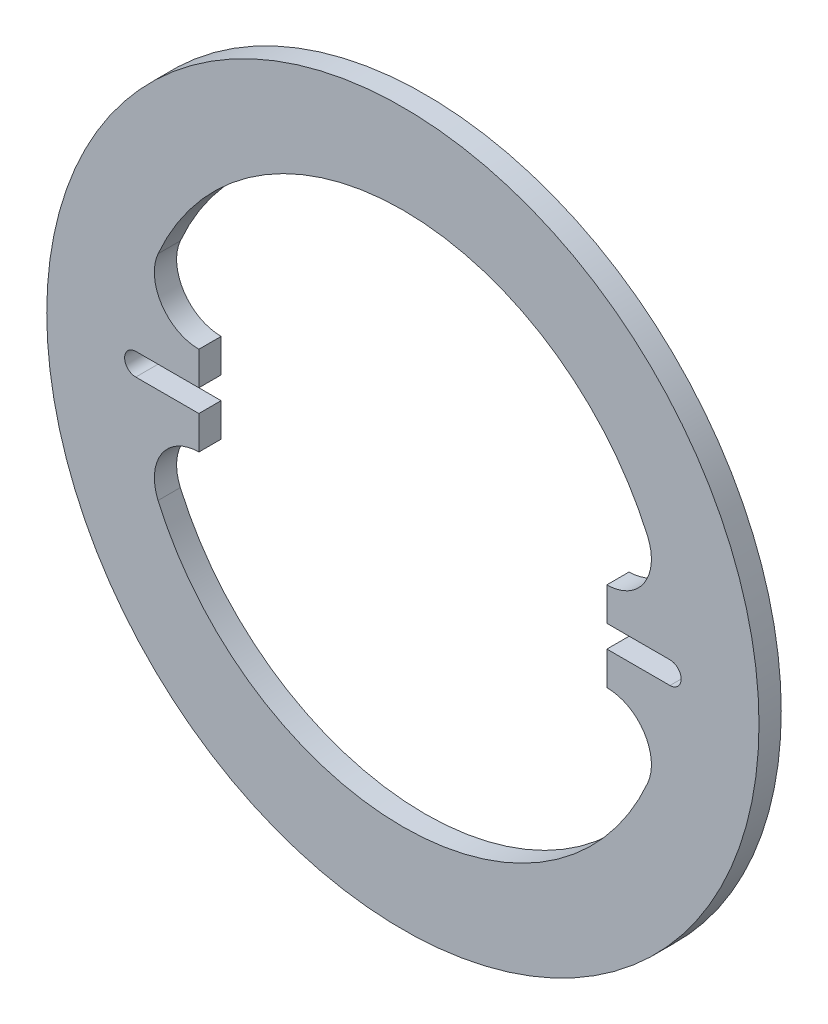
from build123d import *

# Parameters (mm, degrees)
SKETCH1_R           = 101.6
BOSS_EXTRUDE1_DEPTH = 6.35
SKETCH2_R           = 25.4
CUT_EXTRUDE1_DEPTH  = 7.35
CUT_EXTRUDE2_DEPTH  = 7.35
CUT_EXTRUDE3_DEPTH  = 7.35
CUT_EXTRUDE10_DEPTH = 7.35


with BuildPart() as part:
    # Sketch1 → Boss-Extrude1 (new body)
    with BuildSketch(Plane.XY):
        Circle(SKETCH1_R)
    extrude(amount=BOSS_EXTRUDE1_DEPTH)

    # Sketch2 → Cut-Extrude1 (cut, through all)
    with BuildSketch(Plane.XY.offset(6.35)):
        Circle(SKETCH2_R)
    extrude(amount=-CUT_EXTRUDE1_DEPTH, mode=Mode.SUBTRACT)

    # Sketch3 → Cut-Extrude2 (cut, through all)
    with BuildSketch(Plane.XY.offset(6.35)):
        with BuildLine():
            ThreePointArc((69.838453591, 30.48), (0, 76.2), (-69.838453591, 30.48))
            ThreePointArc((-69.838453591, 30.48), (-63.278711326, 13.760257735), (-46.558969061, 20.32))
            ThreePointArc((-46.558969061, 20.32), (0, 50.8), (46.558969061, 20.32))
            ThreePointArc((46.558969061, 20.32), (63.278711326, 13.760257735), (69.838453591, 30.48))
        make_face()
    cut_extrude2 = extrude(amount=-CUT_EXTRUDE2_DEPTH, mode=Mode.SUBTRACT)

    # Mirror1: Cut-Extrude2 across plane
    add(cut_extrude2.mirror(Plane.ZX), mode=Mode.SUBTRACT)

    # Sketch4 → Cut-Extrude3 (cut, through all)
    with BuildSketch(Plane.XY.offset(6.35)):
        with BuildLine():
            Line((76.2, -3.175), (25.4, -3.175))
            ThreePointArc((25.4, -3.175), (22.225, 0), (25.4, 3.175))
            Line((25.4, 3.175), (76.2, 3.175))
            ThreePointArc((76.2, 3.175), (79.375, 0), (76.2, -3.175))
        make_face()
        with BuildLine():
            Line((-76.2, -3.175), (-25.4, -3.175))
            ThreePointArc((-25.4, -3.175), (-22.225, 0), (-25.4, 3.175))
            Line((-25.4, 3.175), (-76.2, 3.175))
            ThreePointArc((-76.2, 3.175), (-79.375, 0), (-76.2, -3.175))
        make_face()
    extrude(amount=-CUT_EXTRUDE3_DEPTH, mode=Mode.SUBTRACT)

    # Sketch14 → Cut-Extrude10 (cut, through all)
    with BuildSketch(Plane.XY.offset(6.35)):
        with BuildLine():
            Line((-58.198711326, -12.7), (-58.198711326, 12.7))
            ThreePointArc((-58.198711326, 12.7), (-51.242634846, 14.774417663), (-46.558969061, 20.32))
            ThreePointArc((-46.558969061, 20.32), (0, 50.8), (46.558969061, 20.32))
            ThreePointArc((46.558969061, 20.32), (51.242634846, 14.774417663), (58.198711326, 12.7))
            Line((58.198711326, 12.7), (58.198711326, -12.7))
            ThreePointArc((58.198711326, -12.7), (51.242634846, -14.774417663), (46.558969061, -20.32))
            ThreePointArc((46.558969061, -20.32), (0, -50.8), (-46.558969061, -20.32))
            ThreePointArc((-46.558969061, -20.32), (-51.242634846, -14.774417663), (-58.198711326, -12.7))
        make_face()
    extrude(amount=-CUT_EXTRUDE10_DEPTH, mode=Mode.SUBTRACT)


solid = part.part
